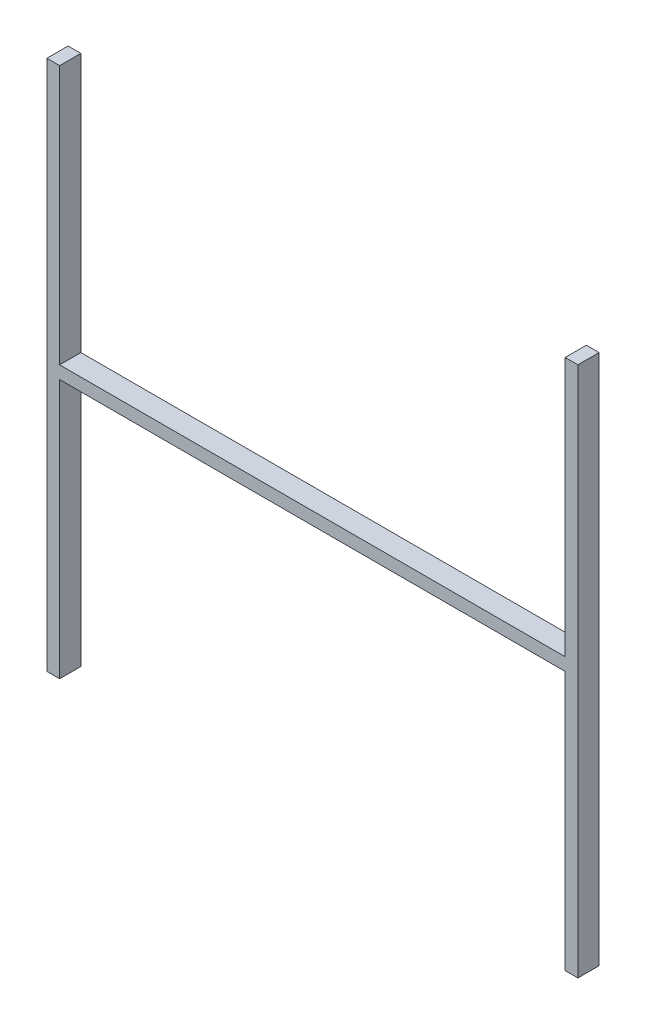
from build123d import *

# Parameters (mm, degrees)
RESSALTO_EXTRUS_O1_DEPTH = 10


with BuildPart() as part:
    # Esboço1 → Ressalto-extrusão1 (new body)
    with BuildSketch(Plane.XY):
        Polygon((-125, 125), (-125, -125), (-119, -125), (-119, -3), (119, -3), (119, -125), (125, -125), (125, 125), (119, 125), (119, 3), (-119, 3), (-119, 125), align=None)
    extrude(amount=RESSALTO_EXTRUS_O1_DEPTH)


solid = part.part
